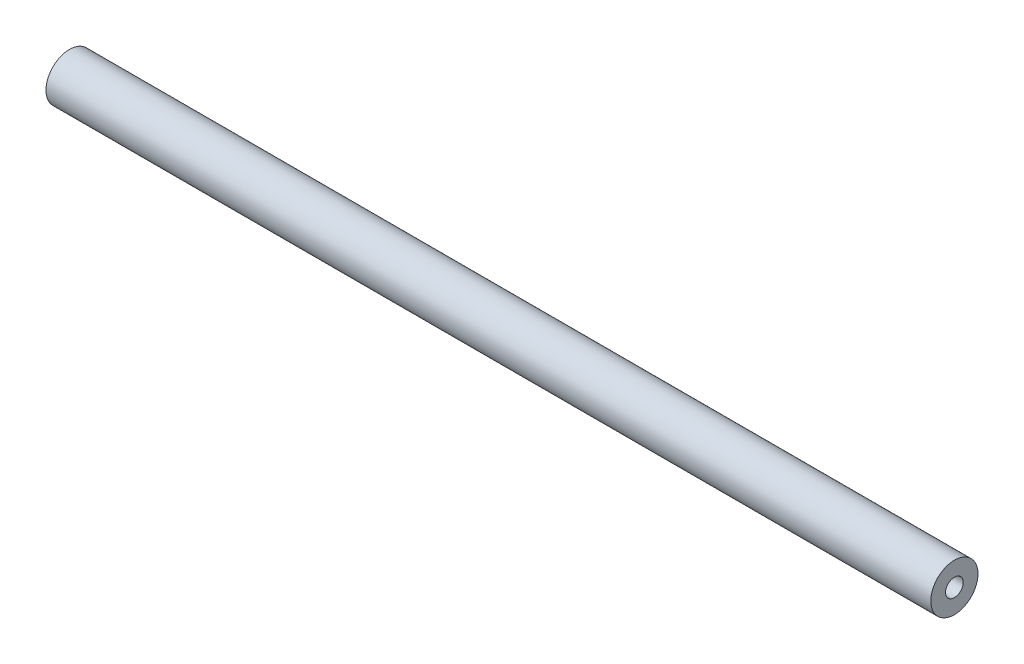
from build123d import *

# Parameters (mm, degrees)
SKETCH1_W = 149.86
SKETCH1_H = 2.5


with BuildPart() as part:
    # Sketch1 → Revolve1 (revolve)
    with BuildSketch(Plane.XY):
        with Locations((74.93, 2.75)):
            Rectangle(SKETCH1_W, SKETCH1_H)
    revolve(axis=Axis((0, 0, 0), (1, 0, 0)))


solid = part.part
